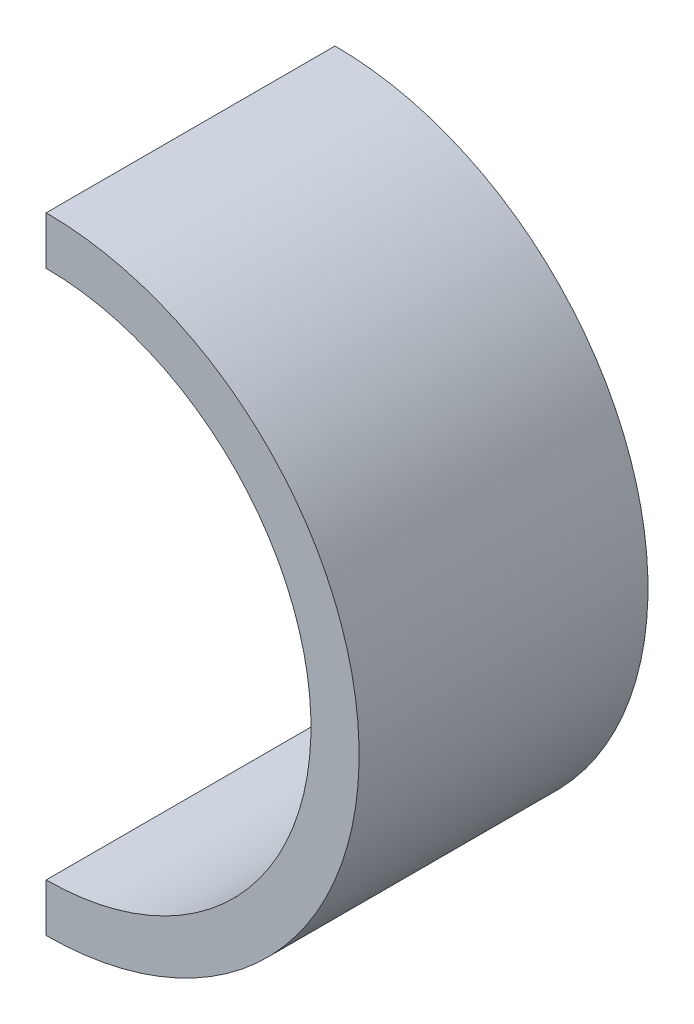
from build123d import *

# Parameters (mm, degrees)
BOSS_EXTRUDE1_DEPTH = 30


with BuildPart() as part:
    # Sketch2 → Boss-Extrude1 (new body)
    with BuildSketch(Plane.XY):
        with BuildLine():
            Line((0, 32.5), (0, 27.5))
            ThreePointArc((0, 27.5), (27.5, 0), (0, -27.5))
            Line((0, -27.5), (0, -32.5))
            ThreePointArc((0, -32.5), (32.5, 0), (0, 32.5))
        make_face()
    extrude(amount=BOSS_EXTRUDE1_DEPTH)


solid = part.part
